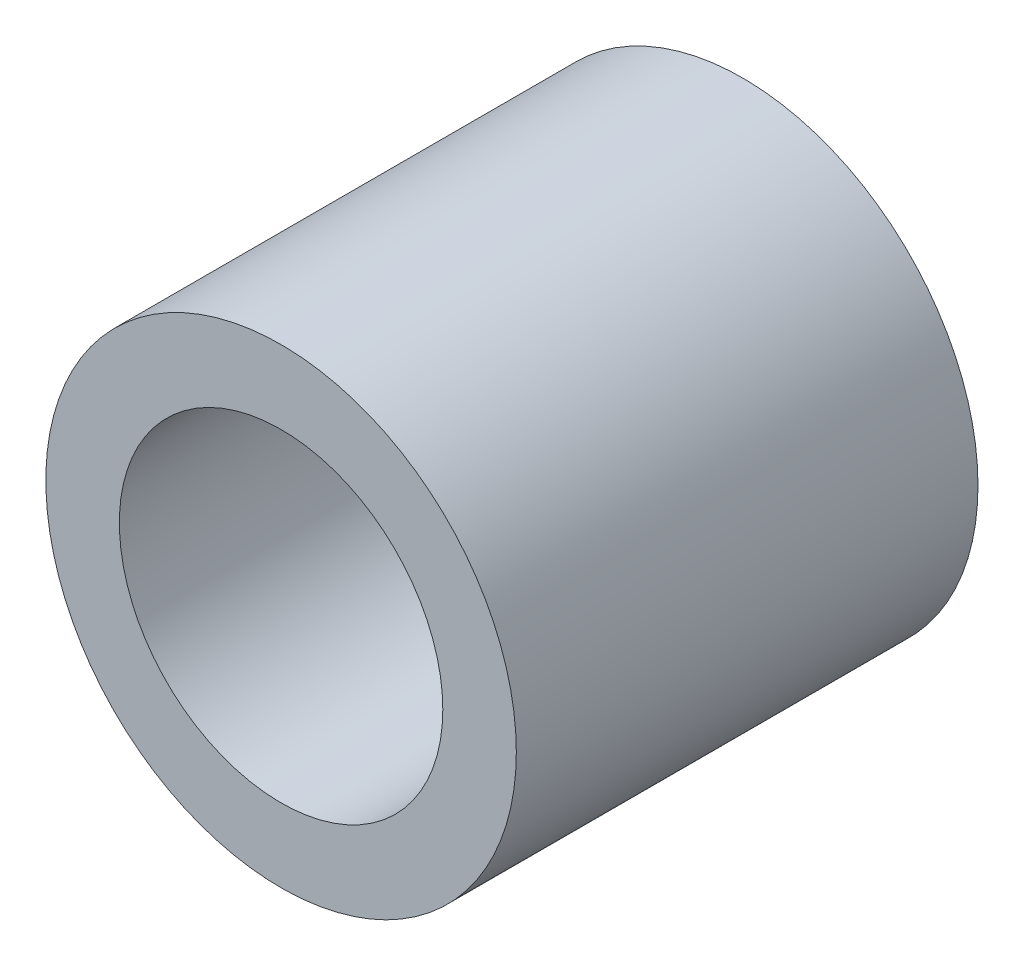
from build123d import *

# Parameters (mm, degrees)
SKETCH1_R           = 4
SKETCH1_R_2         = 2.75
BOSS_EXTRUDE1_DEPTH = 7.85


with BuildPart() as part:
    # Sketch1 → Boss-Extrude1 (new body)
    with BuildSketch(Plane.XY):
        Circle(SKETCH1_R)
        Circle(SKETCH1_R_2, mode=Mode.SUBTRACT)
    extrude(amount=BOSS_EXTRUDE1_DEPTH)


solid = part.part
